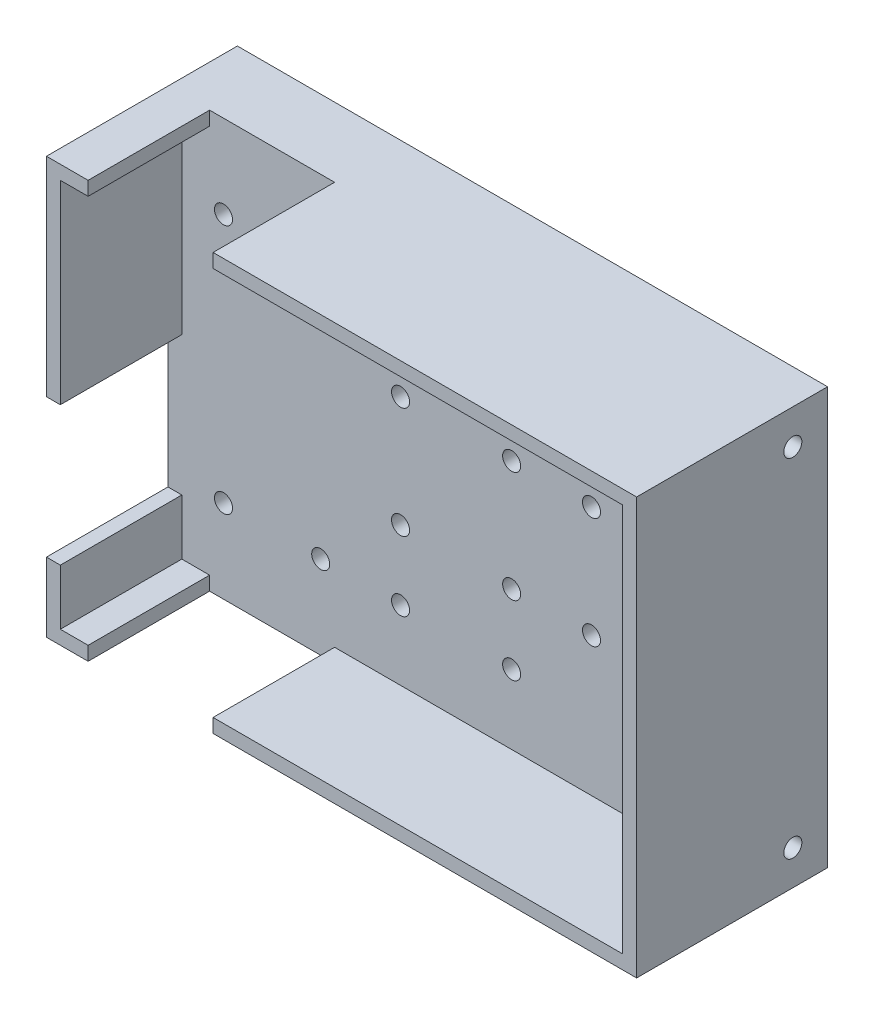
from build123d import *

# Parameters (mm, degrees)
SKETCH1_W          = 76.2
SKETCH1_H          = 107.95
BASE_DEPTH         = 12.7
SKETCH3_W          = 107.95
SKETCH3_H          = 76.2
SKETCH3_W_2        = 102.87
SKETCH3_H_2        = 71.12
WALLS_DEPTH        = 22.225
CUT_EXTRUDE1_DEPTH = 22.225
SKETCH2_R          = 1.650000002
CUT_EXTRUDE2_DEPTH = 6.99999997
SKETCH6_R          = 1.650000002
CUT_EXTRUDE3_DEPTH = 6.99999997
SKETCH7_R          = 1.650000002
CUT_EXTRUDE4_DEPTH = 6.99999997


with BuildPart() as part:
    # Sketch1 → BASE (new body)
    with BuildSketch(Plane(origin=(0, 0, 0), x_dir=(0, 1, 0), z_dir=(0, 0, 1))):
        Rectangle(SKETCH1_W, SKETCH1_H)
    extrude(amount=BASE_DEPTH)

    # Sketch3 → WALLS (add)
    with BuildSketch(Plane.XY.offset(12.7)):
        Rectangle(SKETCH3_W, SKETCH3_H)
        Rectangle(SKETCH3_W_2, SKETCH3_H_2, mode=Mode.SUBTRACT)
    extrude(amount=WALLS_DEPTH)

    # Sketch4 → Cut-Extrude1 (cut)
    with BuildSketch(Plane.XY.offset(34.925)):
        Polygon((-46.355, 38.1), (-23.495, 38.1), (-23.495, -38.1), (-46.355, -38.1), (-46.355, -25.4), (-53.975, -25.4), (-53.975, 0), (-46.355, 0), align=None)
    extrude(amount=-CUT_EXTRUDE1_DEPTH, mode=Mode.SUBTRACT)

    # Sketch2 → Cut-Extrude2 (cut)
    with BuildSketch(Plane.XY.offset(12.7)):
        with Locations((-43.815, 22.86)):
            Circle(SKETCH2_R)
        with Locations((-26.035, 22.86)):
            Circle(SKETCH2_R)
        with Locations((-43.815, -22.86)):
            Circle(SKETCH2_R)
        with Locations((-26.035, -22.86)):
            Circle(SKETCH2_R)
        with Locations((-11.43, -22.86)):
            Circle(SKETCH2_R)
        with Locations((-11.43, -10.16)):
            Circle(SKETCH2_R)
        with Locations((8.89, -10.16)):
            Circle(SKETCH2_R)
        with Locations((8.89, -22.86)):
            Circle(SKETCH2_R)
        with Locations((23.495, -10.16)):
            Circle(SKETCH2_R)
        with Locations((43.815, -10.16)):
            Circle(SKETCH2_R)
        with Locations((43.815, 10.16)):
            Circle(SKETCH2_R)
        with Locations((23.495, 10.16)):
            Circle(SKETCH2_R)
        with Locations((-11.43, 10.16)):
            Circle(SKETCH2_R)
        with Locations((8.89, 22.86)):
            Circle(SKETCH2_R)
        with Locations((-11.43, 22.86)):
            Circle(SKETCH2_R)
        with Locations((8.89, 10.16)):
            Circle(SKETCH2_R)
    extrude(amount=-CUT_EXTRUDE2_DEPTH, mode=Mode.SUBTRACT)

    # Sketch6 → Cut-Extrude3 (cut)
    with BuildSketch(Plane(origin=(-53.975, 0, 0), x_dir=(0, -1, 0), z_dir=(-1, 0, 0))):
        with Locations((-31.75, 6.35)):
            Circle(SKETCH6_R)
        with Locations((31.75, 6.35)):
            Circle(SKETCH6_R)
    extrude(amount=-CUT_EXTRUDE3_DEPTH, mode=Mode.SUBTRACT)

    # Sketch7 → Cut-Extrude4 (cut)
    with BuildSketch(Plane.YZ.offset(53.975)):
        with Locations((-31.75, 6.35)):
            Circle(SKETCH7_R)
        with Locations((31.75, 6.35)):
            Circle(SKETCH7_R)
    extrude(amount=-CUT_EXTRUDE4_DEPTH, mode=Mode.SUBTRACT)


solid = part.part
